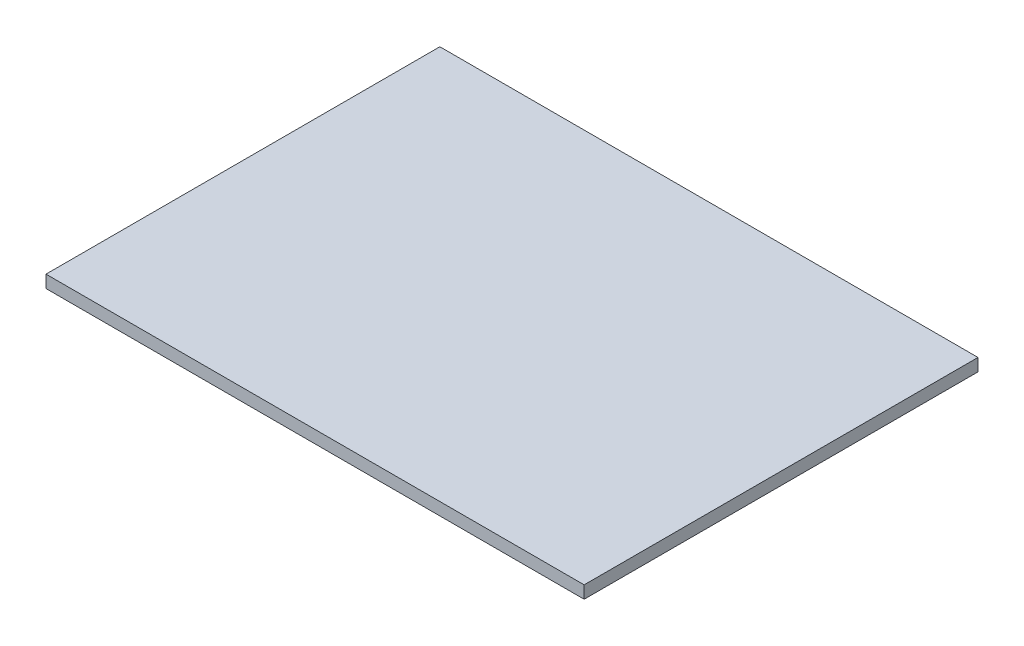
from build123d import *

# Parameters (mm, degrees)
SKETCH1_W           = 819.94375
SKETCH1_H           = 600.075
BOSS_EXTRUDE1_DEPTH = 19.05


with BuildPart() as part:
    # Sketch1 → Boss-Extrude1 (new body)
    with BuildSketch(Plane(origin=(0, 0, 0), x_dir=(1, 0, 0), z_dir=(0, 1, 0))):
        with Locations((409.971875, 300.0375)):
            Rectangle(SKETCH1_W, SKETCH1_H)
    extrude(amount=BOSS_EXTRUDE1_DEPTH)


solid = part.part
